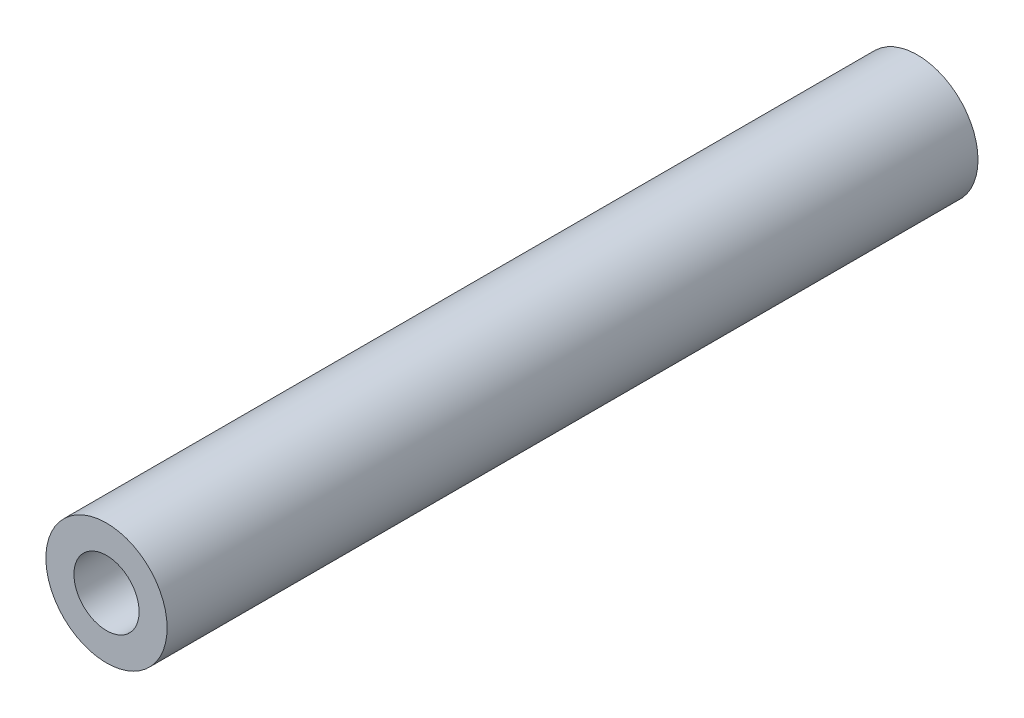
from build123d import *

# Parameters (mm, degrees)
SKETCH1_R           = 4
SKETCH1_R_2         = 2.15
BOSS_EXTRUDE1_DEPTH = 53.5


with BuildPart() as part:
    # Sketch1 → Boss-Extrude1 (new body)
    with BuildSketch(Plane.XY):
        Circle(SKETCH1_R)
        Circle(SKETCH1_R_2, mode=Mode.SUBTRACT)
    extrude(amount=BOSS_EXTRUDE1_DEPTH)


solid = part.part
